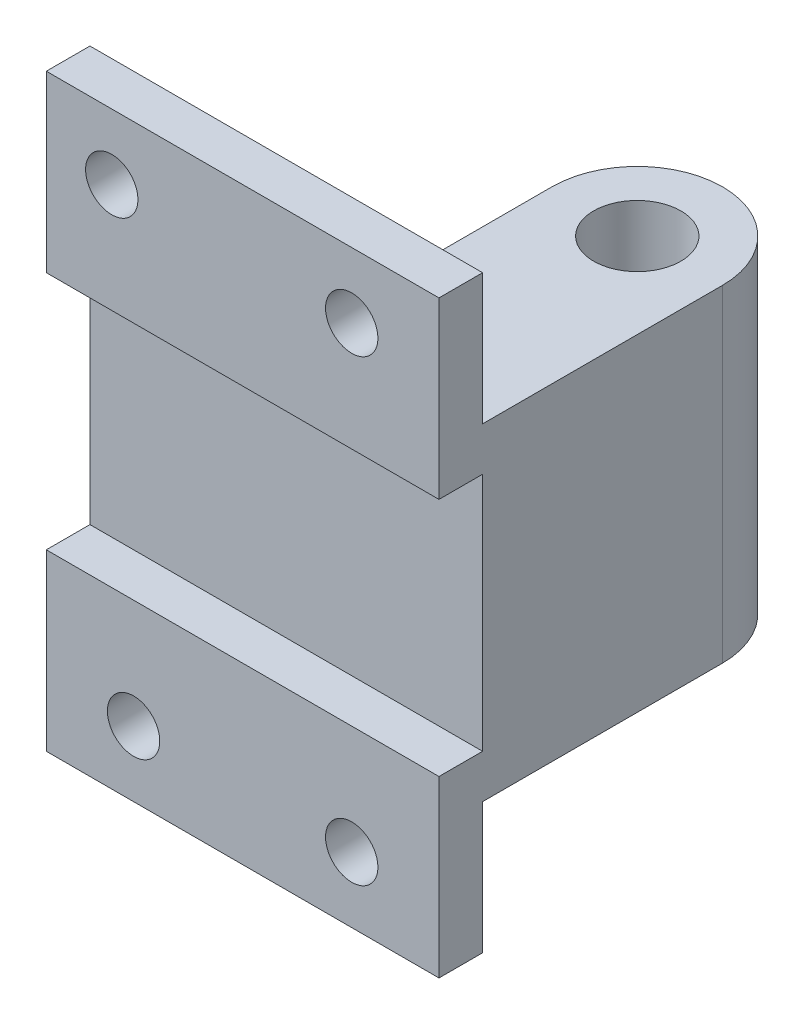
from build123d import *

# Parameters (mm, degrees)
SKETCH4_W           = 90
SKETCH4_H           = 10
BOSS_EXTRUDE3_DEPTH = 135
BOSS_EXTRUDE4_DEPTH = 90
SKETCH6_W           = 10
SKETCH6_H           = 55
CUT_EXTRUDE3_DEPTH  = 130
BOSS_EXTRUDE5_DEPTH = 75
SKETCH8_R           = 10
CUT_EXTRUDE4_DEPTH  = 95
SKETCH11_R          = 6
CUT_EXTRUDE5_DEPTH  = 95
SKETCH12_R          = 6
CUT_EXTRUDE6_DEPTH  = 95
SKETCH13_W          = 6
SKETCH13_H          = 10
BOSS_EXTRUDE6_DEPTH = 30
CUT_EXTRUDE7_DEPTH  = 30
BOSS_EXTRUDE7_DEPTH = 3
CUT_EXTRUDE10_DEPTH = 18
SKETCH18_W          = 6
SKETCH18_H          = 10
BOSS_EXTRUDE8_DEPTH = 30
CUT_EXTRUDE11_DEPTH = 30
SKETCH20_W          = 50.090708896
SKETCH20_H          = 1.471886497
BOSS_EXTRUDE9_DEPTH = 6
SKETCH21_W          = 9.793244498
SKETCH21_H          = 5.326709205
CUT_EXTRUDE12_DEPTH = 6


with BuildPart() as part:
    # Sketch4 → Boss-Extrude3 (new body)
    with BuildSketch(Plane(origin=(0, 0, 0), x_dir=(1, 0, 0), z_dir=(0, 1, 0))):
        with Locations((45, 5)):
            Rectangle(SKETCH4_W, SKETCH4_H)
    extrude(amount=BOSS_EXTRUDE3_DEPTH)

    # Sketch5 → Boss-Extrude4 (add)
    with BuildSketch(Plane(origin=(0, 0, 0), x_dir=(0, 0, -1), z_dir=(1, 0, 0))):
        Polygon((0, 0), (0, 40), (10, 40), (10, 95), (0, 95), (0, 135), (10, 135), (10, 105), (20, 105), (20, 30), (10, 30), (10, 0), align=None)
    extrude(amount=BOSS_EXTRUDE4_DEPTH)

    # Sketch6 → Cut-Extrude3 (cut)
    with BuildSketch(Plane.ZY):
        with Locations((-5, 67.5)):
            Rectangle(SKETCH6_W, SKETCH6_H)
    extrude(amount=-CUT_EXTRUDE3_DEPTH, mode=Mode.SUBTRACT)

    # Sketch7 → Boss-Extrude5 (add)
    with BuildSketch(Plane.XZ.offset(-30)):
        with BuildLine():
            Line((90, -20), (90, -65))
            ThreePointArc((90, -65), (70.445832322, -84.554167678), (50.891664643, -65))
            Line((50.891664643, -65), (50.891664643, -20))
            Line((50.891664643, -20), (90, -20))
        make_face()
    extrude(amount=-BOSS_EXTRUDE5_DEPTH)

    # Sketch8 → Cut-Extrude4 (cut)
    with BuildSketch(Plane.XZ.offset(-30)):
        with Locations((70.445832322, -65)):
            Circle(SKETCH8_R)
    extrude(amount=-CUT_EXTRUDE4_DEPTH, mode=Mode.SUBTRACT)

    # Sketch11 → Cut-Extrude5 (cut)
    with BuildSketch(Plane(origin=(0, 0, -10), x_dir=(-1, 0, 0), z_dir=(0, 0, -1))):
        with Locations((-70, 15)):
            Circle(SKETCH11_R)
        with Locations((-20, 15)):
            Circle(SKETCH11_R)
    extrude(amount=-CUT_EXTRUDE5_DEPTH, mode=Mode.SUBTRACT)

    # Sketch12 → Cut-Extrude6 (cut)
    with BuildSketch(Plane(origin=(0, 0, -10), x_dir=(-1, 0, 0), z_dir=(0, 0, -1))):
        with Locations((-70, 120)):
            Circle(SKETCH12_R)
        with Locations((-15, 120)):
            Circle(SKETCH12_R)
    extrude(amount=-CUT_EXTRUDE6_DEPTH, mode=Mode.SUBTRACT)

    # Sketch13 → Boss-Extrude6 (add)
    with BuildSketch(Plane.XZ.offset(-30)):
        with Locations((42, -15)):
            Rectangle(SKETCH13_W, SKETCH13_H)
    extrude(amount=BOSS_EXTRUDE6_DEPTH)

    # Sketch14 → Cut-Extrude7 (cut)
    with BuildSketch(Plane.ZY.offset(-39)):
        Polygon((-20, 30), (-9.033737426, -2.819084872), (-23.067852081, -4.027904728), (-23.067852081, 30), align=None)
    extrude(amount=-CUT_EXTRUDE7_DEPTH, mode=Mode.SUBTRACT)

    # Sketch16 → Boss-Extrude7 (add, symmetric)
    with BuildSketch(Plane(origin=(0, 70, 0), x_dir=(1, 0, 0), z_dir=(0, 1, 0))):
        with BuildLine():
            Line((50.090708896, 21.471886497), (50.090708896, 65.894352206))
            ThreePointArc((50.090708896, 65.894352206), (51.806699753, 73.025071947), (56.578931041, 78.594416359))
            Line((56.578931041, 78.594416359), (-4.085392515, 78.594416359))
            Line((-4.085392515, 78.594416359), (-4.085392515, 21.471886497))
            Line((-4.085392515, 21.471886497), (50.090708896, 21.471886497))
        make_face()
    extrude(amount=BOSS_EXTRUDE7_DEPTH, both=True)

    # Sketch17 → Cut-Extrude10 (cut, symmetric)
    with BuildSketch(Plane.XZ.offset(-67)):
        Polygon((55.920281495, -78.090983416), (-4.085392515, -21.471886497), (-4.085392515, -120.610546036), (55.920281495, -116.406239738), align=None)
    extrude(amount=CUT_EXTRUDE10_DEPTH, both=True, mode=Mode.SUBTRACT)

    # Sketch18 → Boss-Extrude8 (add)
    with BuildSketch(Plane(origin=(0, 105, 0), x_dir=(1, 0, 0), z_dir=(0, 1, 0))):
        with Locations((42, 15)):
            Rectangle(SKETCH18_W, SKETCH18_H)
    extrude(amount=BOSS_EXTRUDE8_DEPTH)

    # Sketch19 → Cut-Extrude11 (cut)
    with BuildSketch(Plane.ZY.offset(-39)):
        Polygon((-20, 105), (-10, 135), (-32.228945025, 136.35277526), (-34.026284176, 106.818709731), align=None)
    extrude(amount=-CUT_EXTRUDE11_DEPTH, mode=Mode.SUBTRACT)

    # Sketch20 → Boss-Extrude9 (add)
    with BuildSketch(Plane.XZ.offset(-67)):
        with Locations((25.045354448, -20.735943248)):
            Rectangle(SKETCH20_W, SKETCH20_H)
    extrude(amount=-BOSS_EXTRUDE9_DEPTH)

    # Sketch21 → Cut-Extrude12 (cut)
    with BuildSketch(Plane.XZ.offset(-67)):
        with Locations((-4.896622249, -22.663354603)):
            Rectangle(SKETCH21_W, SKETCH21_H)
    extrude(amount=-CUT_EXTRUDE12_DEPTH, mode=Mode.SUBTRACT)


solid = part.part
